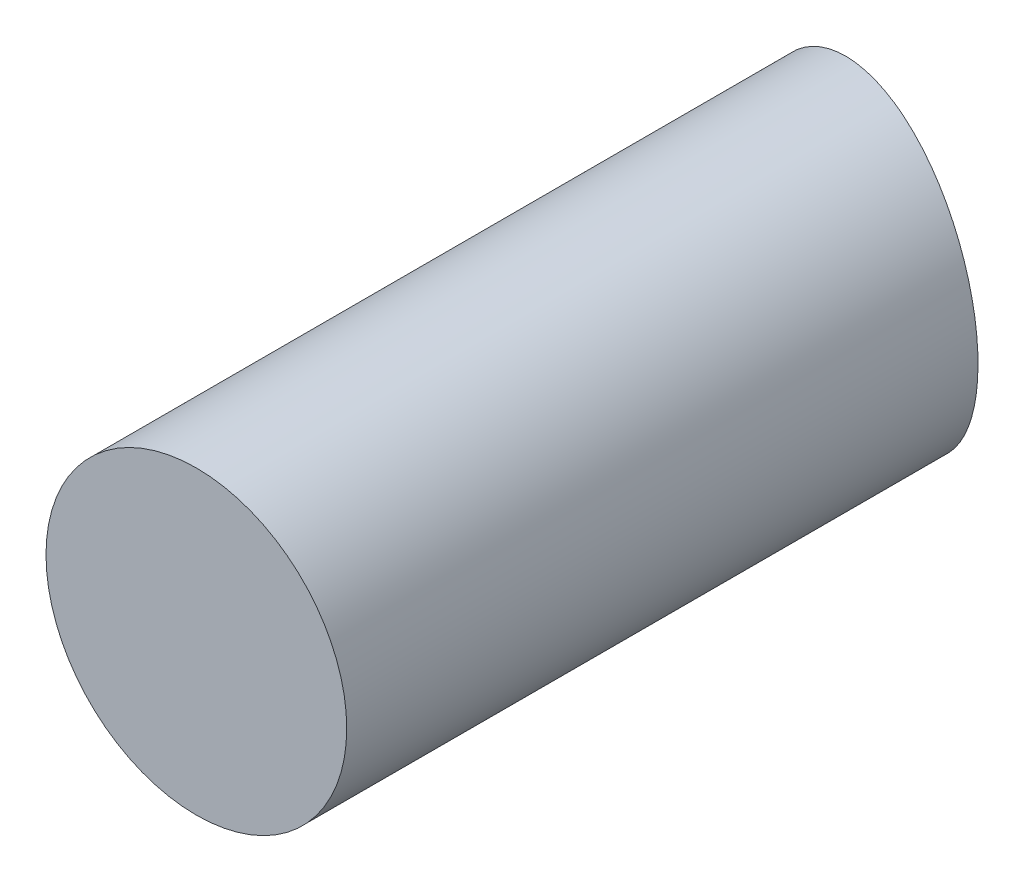
from build123d import *

# Parameters (mm, degrees)
SKETCH1_R               = 4.7625
BOSS_EXTRUDE1_DEPTH     = 25.4
SKETCH2_RX              = 4.7625
SKETCH2_RY              = 1.232625702
SKETCH2_RX_2            = 9.362827468
SKETCH2_RY_2            = 1.051298719
CUT_EXTRUDE1_DEPTH      = 27.277800755
CUT_EXTRUDE1_DEPTH_BACK = 27.277800755


with BuildPart() as part:
    # Sketch1 → Boss-Extrude1 (new body)
    with BuildSketch(Plane.XY):
        Circle(SKETCH1_R)
    extrude(amount=BOSS_EXTRUDE1_DEPTH)

    # Sketch2 → Cut-Extrude1 (cut, two sides)
    with BuildSketch(Plane(origin=(0, 0, 0), x_dir=(0, 1, 0), z_dir=(-0.9659258262890691, 0, -0.2588190451025179))) as cut_extrude1_sk:
        with Locations(Location((0, 0), (0, 0, 180))):
            Ellipse(SKETCH2_RX, SKETCH2_RY)
        with Locations((0, -2.93730779)):
            Ellipse(SKETCH2_RX_2, SKETCH2_RY_2)
    extrude(amount=CUT_EXTRUDE1_DEPTH, mode=Mode.SUBTRACT)
    extrude(cut_extrude1_sk.sketch, amount=-CUT_EXTRUDE1_DEPTH_BACK, mode=Mode.SUBTRACT)


with BuildPart() as cut_extrude1_kept_piece:
    # of the separate pieces the step leaves, the one the design keeps (cut_extrude1_pieces_kept)
    add(part.part.solids().sort_by_distance((-0.996279445, 4.657127174, 3.718165509))[0])


solid = cut_extrude1_kept_piece.part
